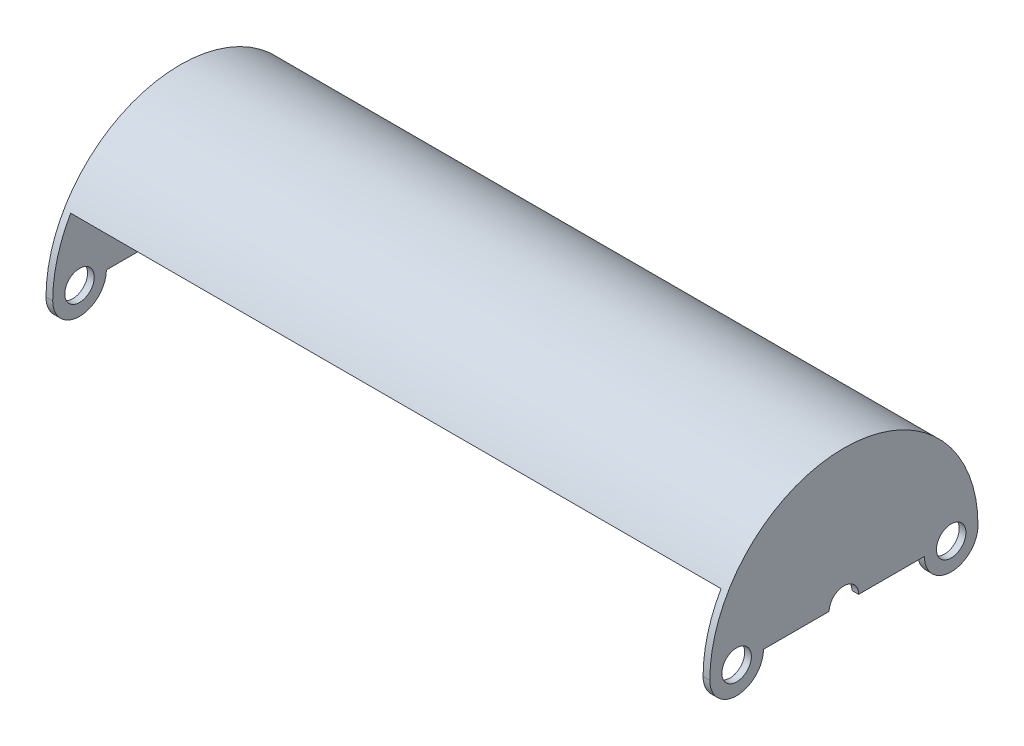
from build123d import *

# Parameters (mm, degrees)
BOSS_EXTRUDE1_DEPTH = 76.99375
SKETCH2_R           = 3.4925
BOSS_EXTRUDE2_DEPTH = 1.5875


with BuildPart() as part:
    # Sketch1 → Boss-Extrude1 (new body, symmetric)
    with BuildSketch(Plane(origin=(0, 0, 0), x_dir=(0, 0, -1), z_dir=(1, 0, 0))):
        with BuildLine():
            ThreePointArc((-26.121491242, 15.08125), (7.806629448, 29.134737735), (30.1625, 0))
            Line((30.1625, 0), (31.75, 0))
            ThreePointArc((31.75, 0), (8.217504682, 30.668144985), (-27.49630657, 15.875))
            Line((-27.49630657, 15.875), (-26.121491242, 15.08125))
        make_face()
    extrude(amount=BOSS_EXTRUDE1_DEPTH, both=True)

    # Sketch2 → Boss-Extrude2 (add)
    with BuildSketch(Plane(origin=(76.99375, 0, 0), x_dir=(0, 0, -1), z_dir=(1, 0, 0))):
        with BuildLine():
            Line((-19.05, 0), (-3.4925, 0))
            ThreePointArc((-3.4925, 0), (0, 3.4925), (3.4925, 0))
            Line((3.4925, 0), (19.05, 0))
            ThreePointArc((19.05, 0), (25.4, -6.35), (31.75, 0))
            ThreePointArc((31.75, 0), (0, 31.75), (-31.75, 0))
            ThreePointArc((-31.75, 0), (-25.4, -6.35), (-19.05, 0))
        make_face()
        with Locations((-25.4, 0)):
            Circle(SKETCH2_R, mode=Mode.SUBTRACT)
        with Locations((25.4, 0)):
            Circle(SKETCH2_R, mode=Mode.SUBTRACT)
    boss_extrude2 = extrude(amount=BOSS_EXTRUDE2_DEPTH)

    # Mirror1: Boss-Extrude2 across plane
    add(boss_extrude2.mirror(Plane(origin=(0, 0, 0), x_dir=(0, 0, 1), z_dir=(1, 0, 0))))


solid = part.part
